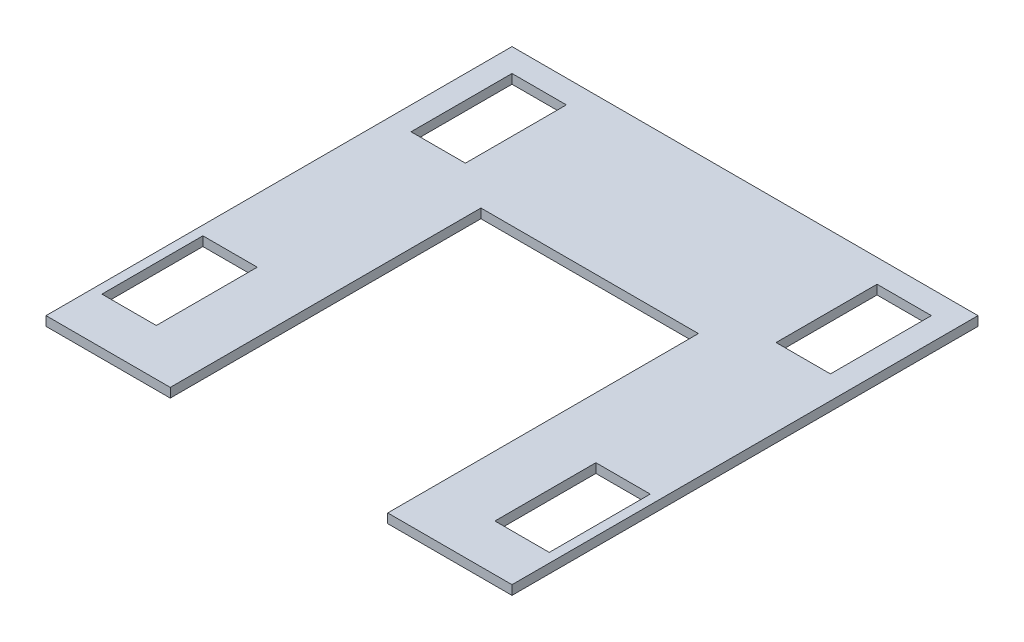
from build123d import *

# Parameters (mm, degrees)
SKETCH1_W           = 35
SKETCH1_H           = 65
BOSS_EXTRUDE1_DEPTH = 6


with BuildPart() as part:
    # Sketch1 → Boss-Extrude1 (new body)
    with BuildSketch(Plane(origin=(0, 0, 0), x_dir=(1, 0, 0), z_dir=(0, 1, 0))):
        Polygon((0, 0), (80, 0), (80, 200), (220, 200), (220, 0), (300, 0), (300, 300), (0, 300), align=None)
        with Locations((32.5, 252.5)):
            Rectangle(SKETCH1_W, SKETCH1_H, mode=Mode.SUBTRACT)
        with Locations((267.5, 252.5)):
            Rectangle(SKETCH1_W, SKETCH1_H, mode=Mode.SUBTRACT)
        with Locations((23.5, 62.5)):
            Rectangle(SKETCH1_W, SKETCH1_H, mode=Mode.SUBTRACT)
        with Locations((276.5, 62.5)):
            Rectangle(SKETCH1_W, SKETCH1_H, mode=Mode.SUBTRACT)
    extrude(amount=BOSS_EXTRUDE1_DEPTH)


solid = part.part
